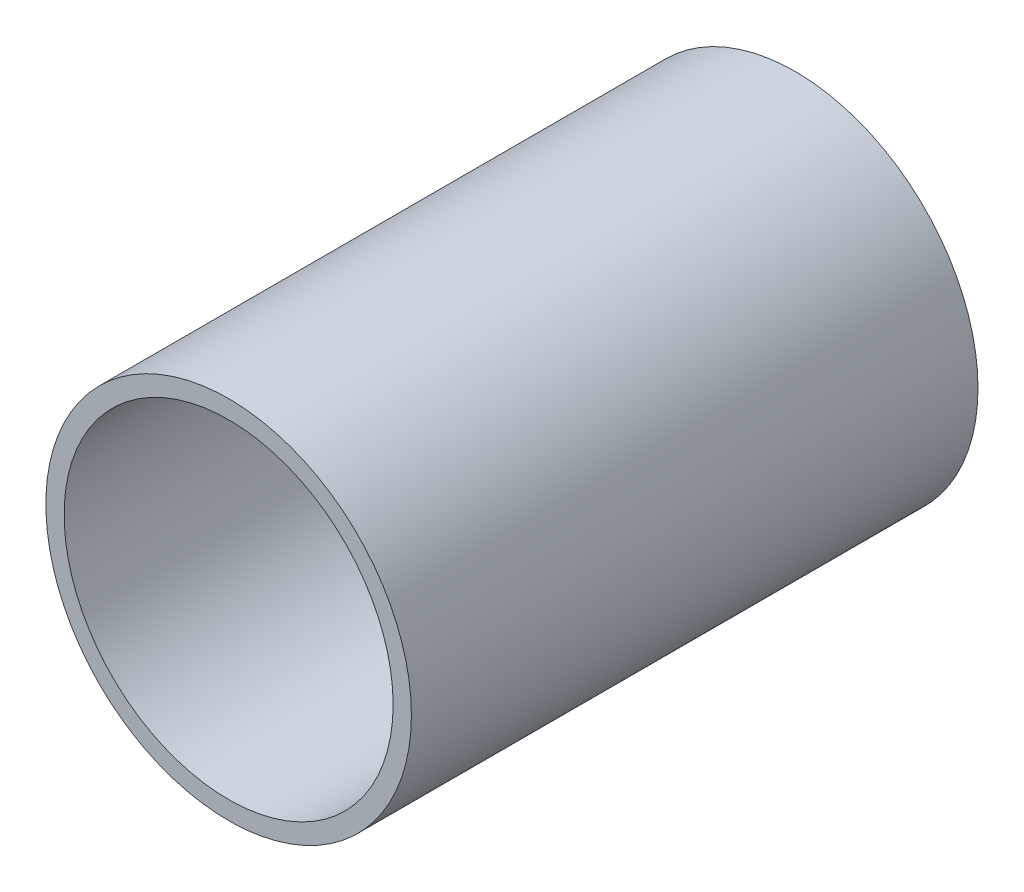
from build123d import *

# Parameters (mm, degrees)
SKETCH1_R           = 10
SKETCH1_R_2         = 9
BOSS_EXTRUDE1_DEPTH = 31


with BuildPart() as part:
    # Sketch1 → Boss-Extrude1 (new body)
    with BuildSketch(Plane.XY):
        Circle(SKETCH1_R)
        Circle(SKETCH1_R_2, mode=Mode.SUBTRACT)
    extrude(amount=BOSS_EXTRUDE1_DEPTH)


solid = part.part
